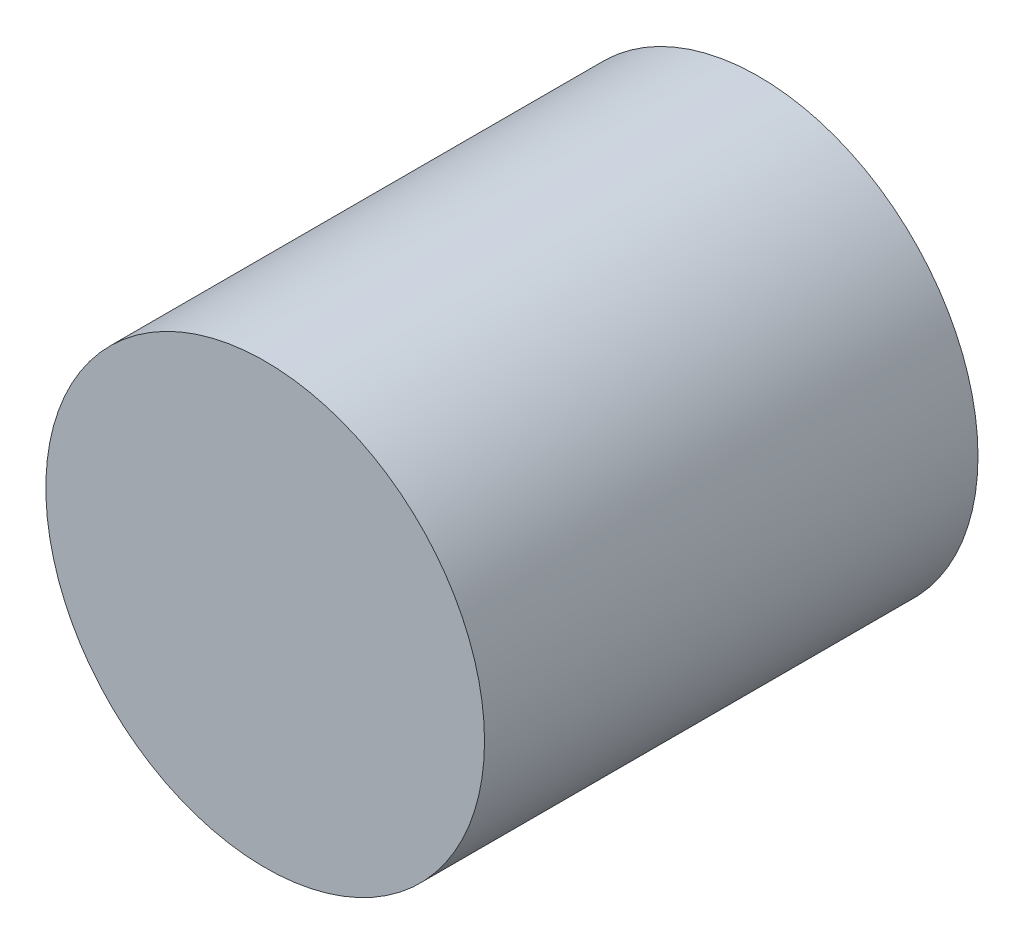
from build123d import *

# Parameters (mm, degrees)
SKETCH1_R           = 1.778
EXTRUDE1_DEPTH      = 1.25
EXTRUDE1_DEPTH_BACK = 2.75


with BuildPart() as part:
    # Sketch1 → Extrude1 (new body, two sides)
    with BuildSketch(Plane.XY) as extrude1_sk:
        with Locations((6.35, 0)):
            Circle(SKETCH1_R)
    extrude(amount=EXTRUDE1_DEPTH)
    extrude(extrude1_sk.sketch, amount=-EXTRUDE1_DEPTH_BACK)


solid = part.part
